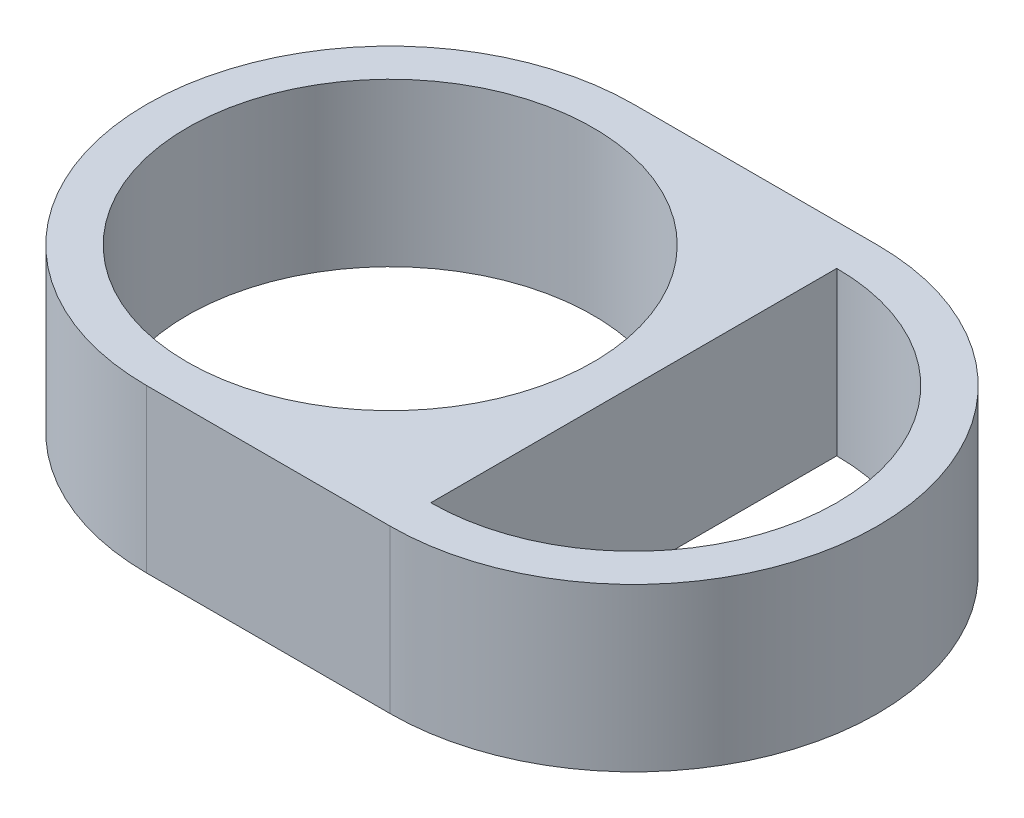
from build123d import *

# Parameters (mm, degrees)
SKETCH_1_R      = 10
EXTRUDE_1_DEPTH = 8


with BuildPart() as part:
    # 草图1 → 凸台-拉伸1 (new body)
    with BuildSketch(Plane(origin=(0, 0, 0), x_dir=(1, 0, 0), z_dir=(0, 1, 0))):
        with BuildLine():
            Line((0, -12), (12, -12))
            ThreePointArc((12, -12), (24, 0), (12, 12))
            Line((12, 12), (0, 12))
            ThreePointArc((0, 12), (-12, 0), (0, -12))
        make_face()
        Circle(SKETCH_1_R, mode=Mode.SUBTRACT)
        with BuildLine():
            Line((12, 10), (12, -10))
            ThreePointArc((12, -10), (22, 0), (12, 10))
        make_face(mode=Mode.SUBTRACT)
    extrude(amount=EXTRUDE_1_DEPTH)


solid = part.part
